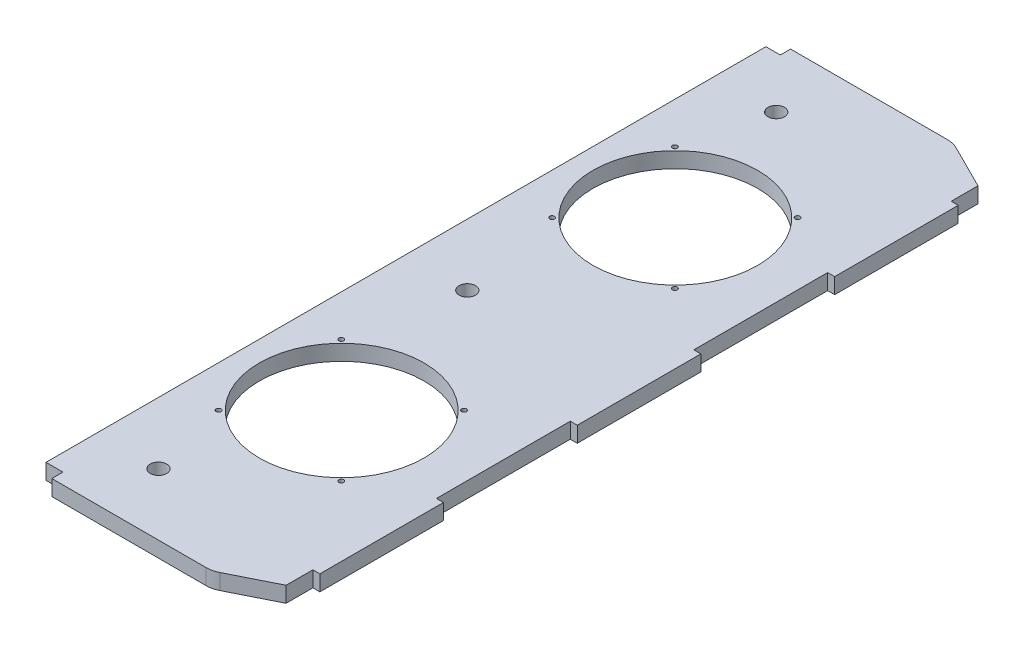
from build123d import *

# Parameters (mm, degrees)
SKETCH1_W                    = 139.7
SKETCH1_H                    = 457.2
SKETCH1_R                    = 50.8
SKETCH1_R_2                  = 5.08
BOSS_EXTRUDE1_DEPTH          = 9.652
SKETCH4_W                    = 10.452383168
SKETCH4_H                    = 6.858
SKETCH4_W_2                  = 8.864883168
SKETCH4_H_2                  = 6.35
CUT_EXTRUDE1_DEPTH           = 10.652
CHAMFER1_SIZE                = 15.24
CHAMFER1_SIZE2               = 30.48
CHAMFER2_SIZE                = 30.48
CHAMFER2_SIZE2               = 15.24
FILLET2_R                    = 15.24
SKETCH5_W                    = 76.2
SKETCH5_H                    = 9.652
BOSS_EXTRUDE2_DEPTH          = 4.318
F_3_0_3_DIAMETER_HOLE1_D     = 3
F_3_0_3_DIAMETER_HOLE1_DEPTH = 9.652


with BuildPart() as part:
    # Sketch1 → Boss-Extrude1 (new body)
    with BuildSketch(Plane(origin=(0, 0, 0), x_dir=(1, 0, 0), z_dir=(0, 1, 0))):
        with Locations((69.85, 228.6)):
            Rectangle(SKETCH1_W, SKETCH1_H)
        with Locations((63.5, 125.73)):
            Circle(SKETCH1_R, mode=Mode.SUBTRACT)
        with Locations((38.1, 38.1)):
            Circle(SKETCH1_R_2, mode=Mode.SUBTRACT)
        with Locations((38.1, 419.1)):
            Circle(SKETCH1_R_2, mode=Mode.SUBTRACT)
        with Locations((63.5, 331.47)):
            Circle(SKETCH1_R, mode=Mode.SUBTRACT)
        with Locations((38.1, 228.6)):
            Circle(SKETCH1_R_2, mode=Mode.SUBTRACT)
    extrude(amount=BOSS_EXTRUDE1_DEPTH)

    # Sketch4 → Cut-Extrude1 (cut, through all)
    with BuildSketch(Plane(origin=(0, 9.652, 0), x_dir=(1, 0, 0), z_dir=(0, 1, 0))):
        with Locations((5.226191584, 3.429)):
            Rectangle(SKETCH4_W, SKETCH4_H)
        with Locations((4.432441584, 454.025)):
            Rectangle(SKETCH4_W_2, SKETCH4_H_2)
    extrude(amount=-CUT_EXTRUDE1_DEPTH, mode=Mode.SUBTRACT)

    # Chamfer1
    chamfer1_edges = [part.edges().sort_by_distance(p)[0] for p in [
        (139.7, 4.826, -457.2),
    ]]
    chamfer1_side = [part.faces().sort_by_distance(p)[0] for p in [
        (139.7, 4.826, -228.6),
    ]]
    chamfer(chamfer1_edges, length=CHAMFER1_SIZE, length2=CHAMFER1_SIZE2, reference=chamfer1_side[0])

    # Chamfer2
    chamfer2_edges = [part.edges().sort_by_distance(p)[0] for p in [
        (139.7, 4.826, 0),
    ]]
    chamfer2_side = [part.faces().sort_by_distance(p)[0] for p in [
        (75.076191584, 4.826, 0),
    ]]
    chamfer(chamfer2_edges, length=CHAMFER2_SIZE, length2=CHAMFER2_SIZE2, reference=chamfer2_side[0])

    # Fillet2
    fillet2_edges = [part.edges().sort_by_distance(p)[0] for p in [
        (109.22, 4.826, -457.2),
        (109.22, 4.826, 0),
    ]]
    fillet(fillet2_edges, radius=FILLET2_R)

    # Sketch5 → Boss-Extrude2 (add)
    with BuildSketch(Plane(origin=(139.7, 0, 0), x_dir=(0, 0, -1), z_dir=(1, 0, 0))):
        with Locations((69.85, 4.826)):
            Rectangle(SKETCH5_W, SKETCH5_H)
        with Locations((228.6, 4.826)):
            Rectangle(SKETCH5_W, SKETCH5_H)
        with Locations((387.35, 4.826)):
            Rectangle(SKETCH5_W, SKETCH5_H)
    extrude(amount=BOSS_EXTRUDE2_DEPTH)

    # Ø3.0 (3) Diameter Hole1
    with Locations(Plane(origin=(0, 9.652, 0), x_dir=(1, 0, 0), z_dir=(0, 1, 0))):
        with Locations((101.092, 87.884), (25.4, 87.884), (25.4, 163.576), (101.092, 163.576)):
            f_3_0_3_diameter_hole1 = Hole(F_3_0_3_DIAMETER_HOLE1_D / 2, depth=F_3_0_3_DIAMETER_HOLE1_DEPTH)

    # Mirror1: Ø3.0 (3) Diameter Hole1 across plane
    add(f_3_0_3_diameter_hole1.mirror(Plane.XY.offset(-228.6)), mode=Mode.SUBTRACT)


solid = part.part
